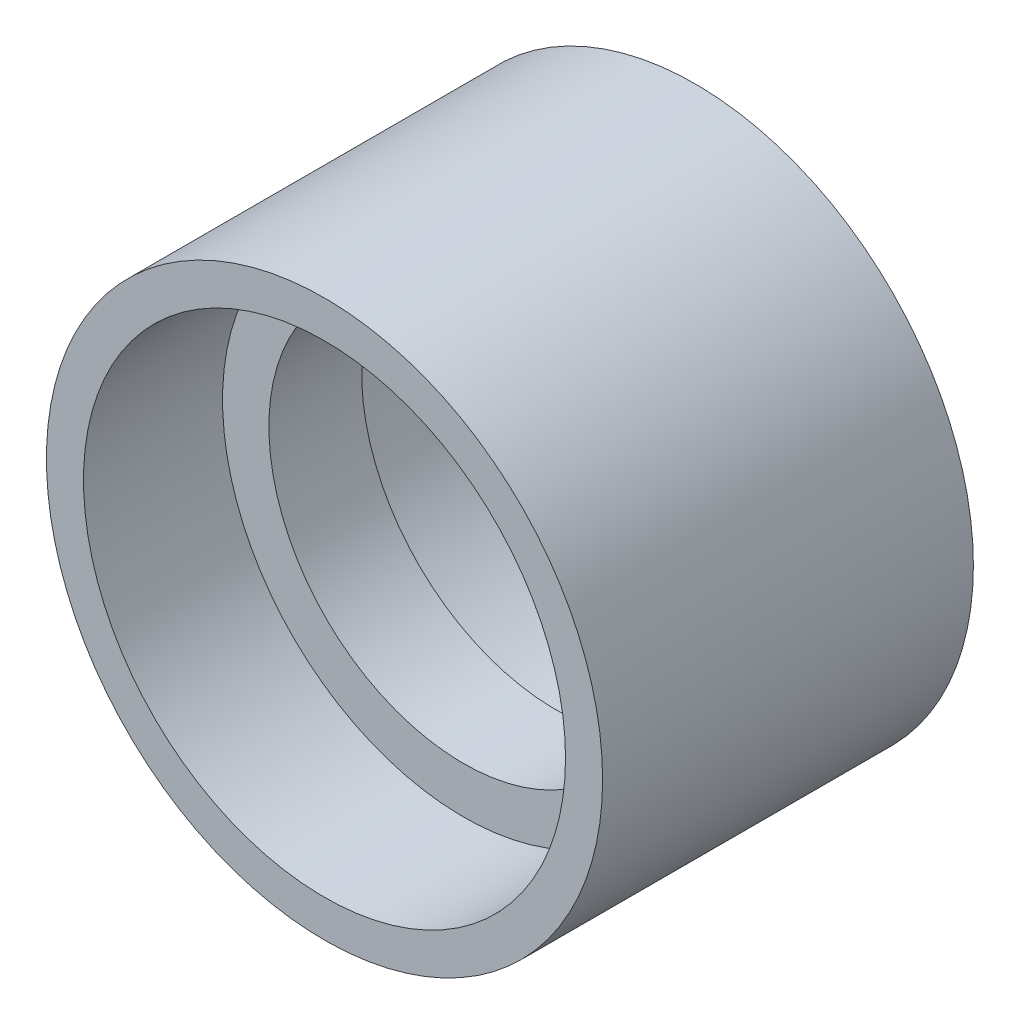
from build123d import *


with BuildPart() as part:
    # Эскиз1 → Повернуть1 (revolve)
    with BuildSketch(Plane(origin=(0, 0, 0), x_dir=(0, 0, -1), z_dir=(1, 0, 0))):
        Polygon((20, 30), (20, 26), (5, 26), (5, 21), (0, 21), (0, 30), align=None)
    revolve(axis=Axis((0, 0, 1000), (0, 0, -1)))

    # Зеркальное отражение1: part across plane


with BuildPart() as part_1:
    add(part.part)
    add(part.part.mirror(Plane(origin=(0, 21, 0), x_dir=(1, 0, 0), z_dir=(0, 0, -1))))


solid = part_1.part
